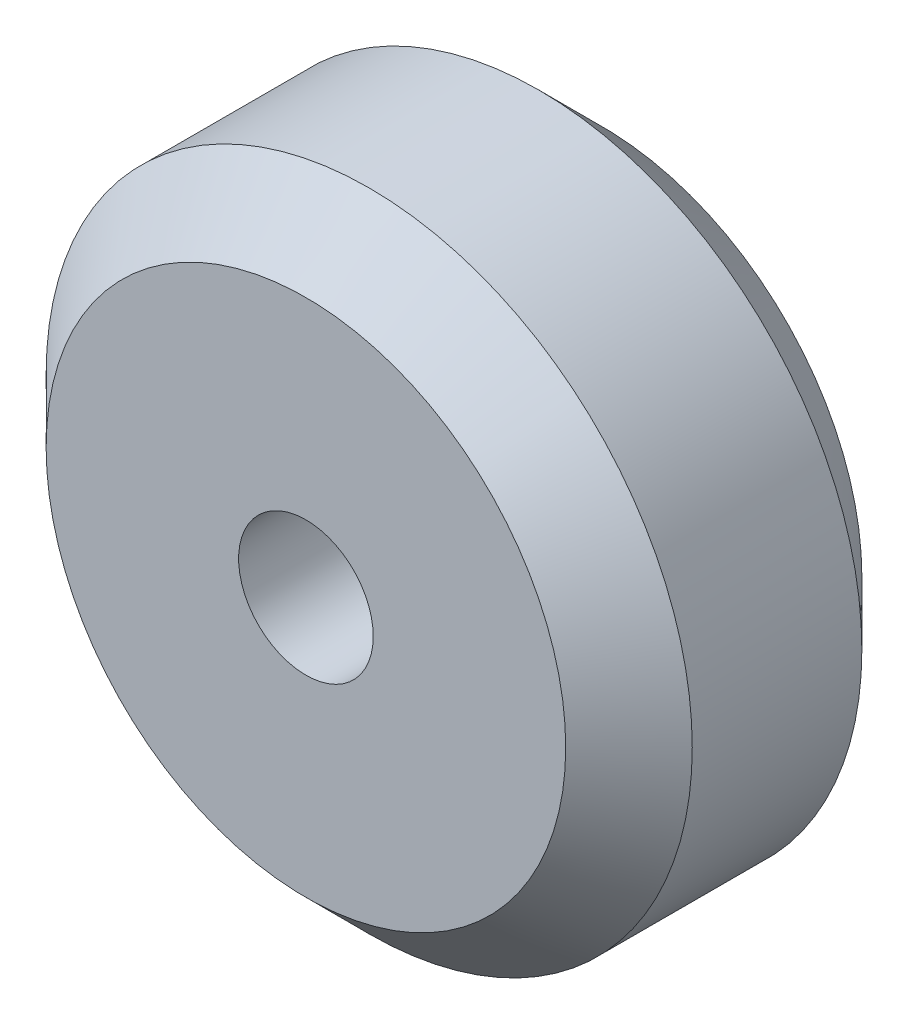
from build123d import *


with BuildPart() as part:
    # Sketch1 → Revolve1 (revolve)
    with BuildSketch(Plane(origin=(0, 0, 0), x_dir=(1, 0, 0), z_dir=(0, 1, 0))):
        Polygon((2.5, 0), (9.65, 0), (12, 2.35), (12, 8.65), (9.65, 11), (2.5, 11), align=None)
    revolve(axis=Axis((0, 0, 0), (0, 0, -1)))


solid = part.part
